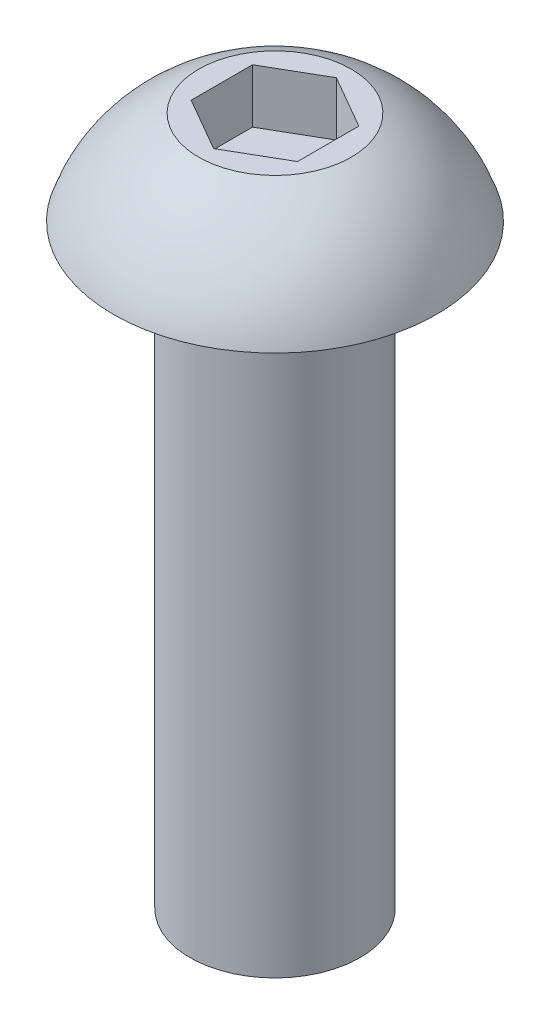
from build123d import *

# Parameters (mm, degrees)
CUT_EXTRUDE1_DEPTH = 1.27


with BuildPart() as part:
    # Sketch1 → Revolve1 (revolve)
    with BuildSketch(Plane.XY):
        with BuildLine():
            Line((-2, 0), (-3.8, 0))
            ThreePointArc((-3.8, 0), (-3.038270032, 1.319559026), (-1.79477003, 2.2))
            Line((-1.79477003, 2.2), (0, 2.2))
            Line((0, 2.2), (0, -14))
            Line((0, -14), (-2, -14))
            Line((-2, -14), (-2, 0))
        make_face()
    revolve(axis=Axis((0, -14, 0), (0, 1, 0)))

    # Sketch2 → Cut-Extrude1 (cut)
    with BuildSketch(Plane(origin=(0, 2.2, 0), x_dir=(1, 0, 0), z_dir=(0, 1, 0))):
        Polygon((-1.25, 0.721687836), (-1.25, -0.721687836), (0, -1.443375673), (1.25, -0.721687836), (1.25, 0.721687836), (0, 1.443375673), align=None)
    extrude(amount=-CUT_EXTRUDE1_DEPTH, mode=Mode.SUBTRACT)


solid = part.part
